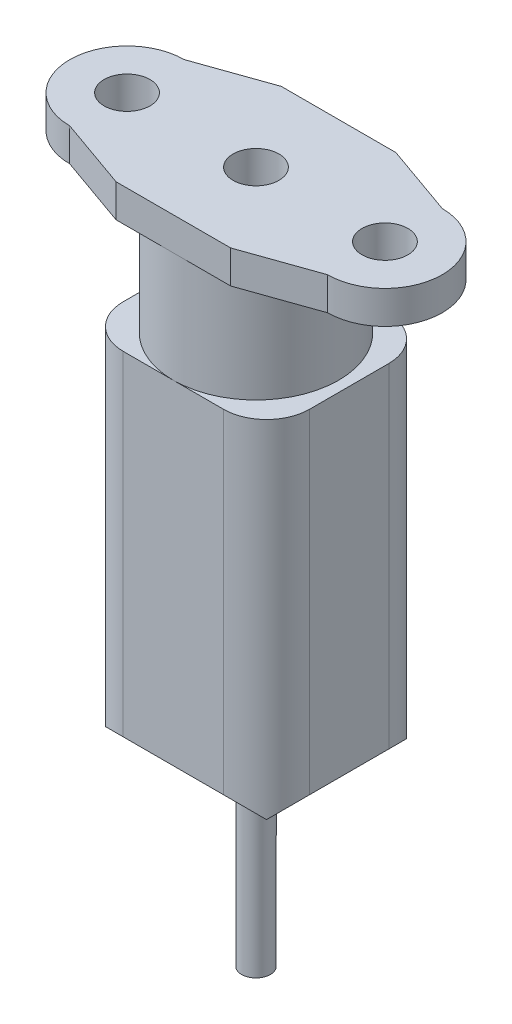
from build123d import *

# Parameters (mm, degrees)
SKETCH1_R           = 1.6
BOSS_EXTRUDE1_DEPTH = 2.3
SKETCH2_R           = 5.765
BOSS_EXTRUDE2_DEPTH = 7.7
SKETCH3_W           = 13
SKETCH3_H           = 11.53
BOSS_EXTRUDE3_DEPTH = 26.3
SKETCH4_R           = 1
BOSS_EXTRUDE4_DEPTH = 12
CHAMFER1_SIZE       = 3
FILLET1_R           = 3


with BuildPart() as part:
    # Sketch1 → Boss-Extrude1 (new body)
    with BuildSketch(Plane.XZ.offset(2.3)):
        with BuildLine():
            Line((-75.699998599, -20.764999665), (-67.699998599, -20.764999665))
            Line((-67.699998599, -20.764999665), (-62.699998599, -18.999999665))
            ThreePointArc((-62.699998599, -18.999999665), (-58.699998599, -14.999999665), (-62.699998599, -10.999999665))
            Line((-62.699998599, -10.999999665), (-67.699998599, -9.234999665))
            Line((-67.699998599, -9.234999665), (-75.699998599, -9.234999665))
            Line((-75.699998599, -9.234999665), (-80.699998599, -10.999999665))
            ThreePointArc((-80.699998599, -10.999999665), (-84.699998599, -14.999999665), (-80.699998599, -18.999999665))
            Line((-80.699998599, -18.999999665), (-75.699998599, -20.764999665))
        make_face()
        with Locations((-62.699998599, -14.999999665)):
            Circle(SKETCH1_R, mode=Mode.SUBTRACT)
        with Locations((-71.699998599, -14.999999665)):
            Circle(SKETCH1_R, mode=Mode.SUBTRACT)
        with Locations((-80.699998599, -14.999999665)):
            Circle(SKETCH1_R, mode=Mode.SUBTRACT)
    extrude(amount=-BOSS_EXTRUDE1_DEPTH)

    # Sketch2 → Boss-Extrude2 (add)
    with BuildSketch(Plane.XZ.offset(2.3)):
        with Locations((-71.699998599, -14.999999665)):
            Circle(SKETCH2_R)
    extrude(amount=BOSS_EXTRUDE2_DEPTH)

    # Sketch3 → Boss-Extrude3 (add)
    with BuildSketch(Plane.XZ.offset(10)):
        with Locations((-71.699998599, -14.999999665)):
            Rectangle(SKETCH3_W, SKETCH3_H)
    extrude(amount=BOSS_EXTRUDE3_DEPTH)

    # Sketch4 → Boss-Extrude4 (add)
    with BuildSketch(Plane.XZ.offset(36.3)):
        with Locations((-71.699998599, -14.999999665)):
            Circle(SKETCH4_R)
    extrude(amount=BOSS_EXTRUDE4_DEPTH)

    # Chamfer1
    chamfer1_edges = [part.edges().sort_by_distance(p)[0] for p in [
        (-71.699998599, -36.3, -9.234999665),
        (-78.199998599, -36.3, -14.999999665),
        (-71.699998599, -36.3, -20.764999665),
        (-65.199998599, -36.3, -14.999999665),
    ]]
    chamfer(chamfer1_edges, length=CHAMFER1_SIZE)

    # Fillet1
    fillet1_edges = [part.edges().sort_by_distance(p)[0] for p in [
        (-78.199998599, -21.65, -20.764999665),
        (-78.199998599, -21.65, -9.234999665),
        (-65.199998599, -21.65, -9.234999665),
        (-65.199998599, -21.65, -20.764999665),
    ]]
    fillet(fillet1_edges, radius=FILLET1_R)


solid = part.part
